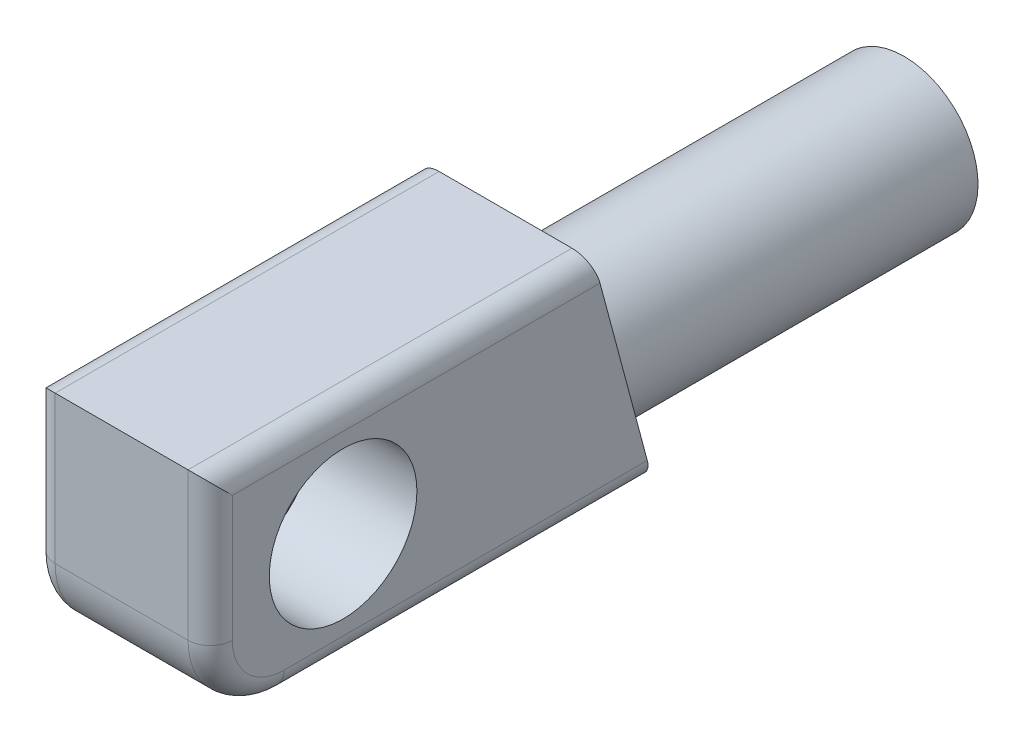
from build123d import *

# Parameters (mm, degrees)
BOSS_EXTRUDE1_DEPTH = 6
SKETCH2_R           = 4
BOSS_EXTRUDE2_DEPTH = 40
CUT_EXTRUDE1_START  = -1
SKETCH3_R           = 5
CUT_EXTRUDE1_DEPTH  = 8
FILLET1_R           = 5
FILLET2_R           = 1.5


with BuildPart() as part:
    # Sketch1 → Boss-Extrude1 (new body, symmetric)
    with BuildSketch(Plane(origin=(0, 0, 0), x_dir=(0, 0, -1), z_dir=(1, 0, 0))):
        Polygon((13, 7.5), (17, -7.5), (-13, -7.5), (-13, 7.5), align=None)
    extrude(amount=BOSS_EXTRUDE1_DEPTH, both=True)

    # Sketch2 → Boss-Extrude2 (add)
    with BuildSketch(Plane.XY):
        with BuildLine():
            Line((-1, -7.5), (1, -7.5))
            Line((1, -7.5), (1, -6.898979486))
            ThreePointArc((1, -6.898979486), (0, 3), (-1, -6.898979486))
            Line((-1, -6.898979486), (-1, -7.5))
        make_face()
        with Locations((0, -2)):
            Circle(SKETCH2_R, mode=Mode.SUBTRACT)
    extrude(amount=-BOSS_EXTRUDE2_DEPTH)

    # Sketch3 → Cut-Extrude1 (cut, through all)
    with BuildSketch(Plane(origin=(0, 0, 0), x_dir=(0, 0, -1), z_dir=(1, 0, 0)).offset(CUT_EXTRUDE1_START)):
        with Locations((-4, 0)):
            Circle(SKETCH3_R)
    extrude(amount=CUT_EXTRUDE1_DEPTH, mode=Mode.SUBTRACT)

    # Fillet1
    fillet1_edges = [part.edges().sort_by_distance(p)[0] for p in [
        (0, -7.5, 13),
    ]]
    fillet(fillet1_edges, radius=FILLET1_R)

    # Fillet2
    fillet2_edges = [part.edges().sort_by_distance(p)[0] for p in [
        (6, -7.5, -4.5),
        (-6, -7.5, -4.5),
        (-6, -6.035533906, 11.535533906),
        (6, -6.035533906, 11.535533906),
        (6, 7.5, 0),
        (-6, 2.5, 13),
        (-6, 7.5, 0),
        (6, 2.5, 13),
    ]]
    fillet(fillet2_edges, radius=FILLET2_R)


solid = part.part
